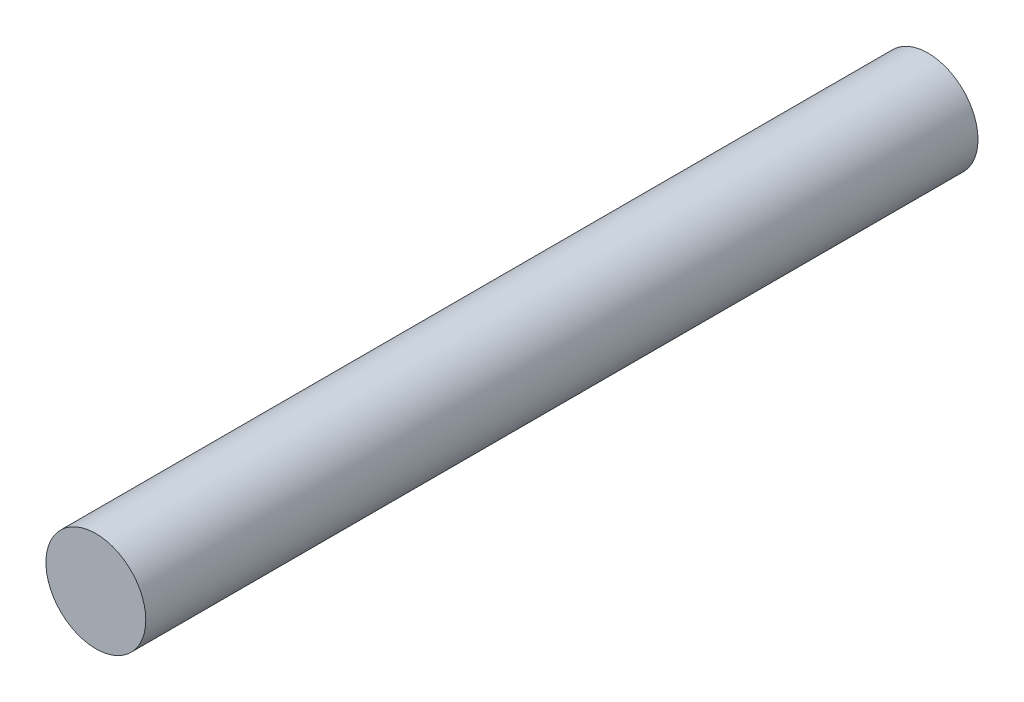
from build123d import *

# Parameters (mm, degrees)
SKETCH1_R           = 3
BOSS_EXTRUDE1_DEPTH = 50


with BuildPart() as part:
    # Sketch1 → Boss-Extrude1 (new body)
    with BuildSketch(Plane.XY):
        Circle(SKETCH1_R)
    extrude(amount=BOSS_EXTRUDE1_DEPTH)


solid = part.part
